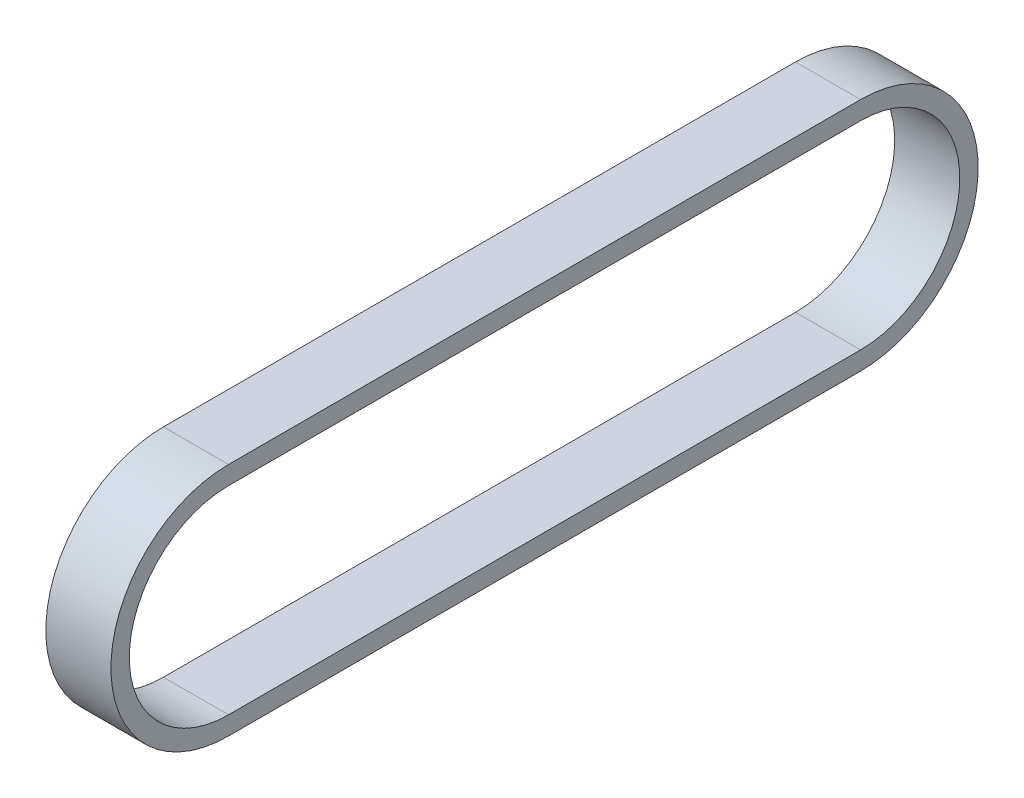
from build123d import *

# Parameters (mm, degrees)
EXTRUDE_THIN1_DEPTH = 9


with BuildPart() as part:
    # Sketch1 → Extrude-Thin1 (new body)
    with BuildSketch(Plane(origin=(0, 0, 0), x_dir=(0, 0, -1), z_dir=(1, 0, 0))):
        with BuildLine():
            Line((87.376, 16.256), (0, 16.256))
            ThreePointArc((0, 16.256), (-16.256, 0), (0, -16.256))
            Line((0, -16.256), (87.376, -16.256))
            ThreePointArc((87.376, -16.256), (103.632, 0), (87.376, 16.256))
        make_face()
        with BuildLine():
            Line((87.376, 13.716), (0, 13.716))
            ThreePointArc((0, 13.716), (-13.716, 0), (0, -13.716))
            Line((0, -13.716), (87.376, -13.716))
            ThreePointArc((87.376, -13.716), (101.092, 0), (87.376, 13.716))
        make_face(mode=Mode.SUBTRACT)
    extrude(amount=EXTRUDE_THIN1_DEPTH)


solid = part.part
